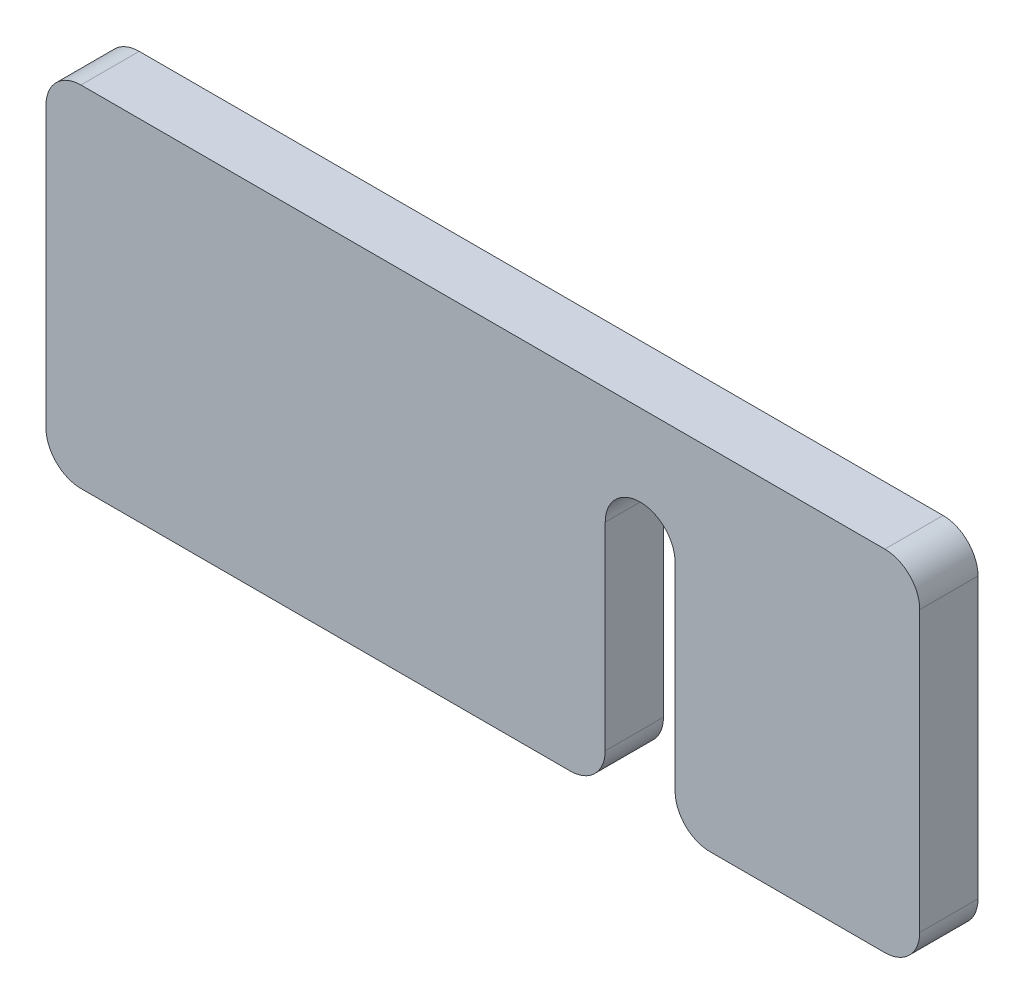
from build123d import *

# Parameters (mm, degrees)
PLAT_W                      = 30
PLAT_H                      = 5
EL_MENT_M_CANO_SOUD_1_DEPTH = 75
ENL_V_MAT_EXTRU_1_DEPTH     = 6
CONG_1_R                    = 3


with BuildPart() as part:
    # plat → Elément mécano-soudé1 (new body)
    with BuildSketch(Plane.YZ.offset(-37.5)):
        Rectangle(PLAT_W, PLAT_H)
    extrude(amount=EL_MENT_M_CANO_SOUD_1_DEPTH)

    # Esquisse2 → Enlèv. mat.-Extru.1 (cut, through all)
    with BuildSketch(Plane(origin=(0, 0, -2.5), x_dir=(-1, 0, 0), z_dir=(0, 0, -1))):
        with BuildLine():
            Line((-16.5, -15), (-10.5, -15))
            Line((-10.5, -15), (-10.5, 5))
            ThreePointArc((-10.5, 5), (-13.5, 8), (-16.5, 5))
            Line((-16.5, 5), (-16.5, -15))
        make_face()
    extrude(amount=-ENL_V_MAT_EXTRU_1_DEPTH, mode=Mode.SUBTRACT)

    # Congé1
    cong_1_edges = [part.edges().sort_by_distance(p)[0] for p in [
        (37.5, 15, 0),
        (16.5, -15, 0),
        (10.5, -15, 0),
        (37.5, -15, 0),
        (-37.5, 15, 0),
        (-37.5, -15, 0),
    ]]
    fillet(cong_1_edges, radius=CONG_1_R)


solid = part.part
